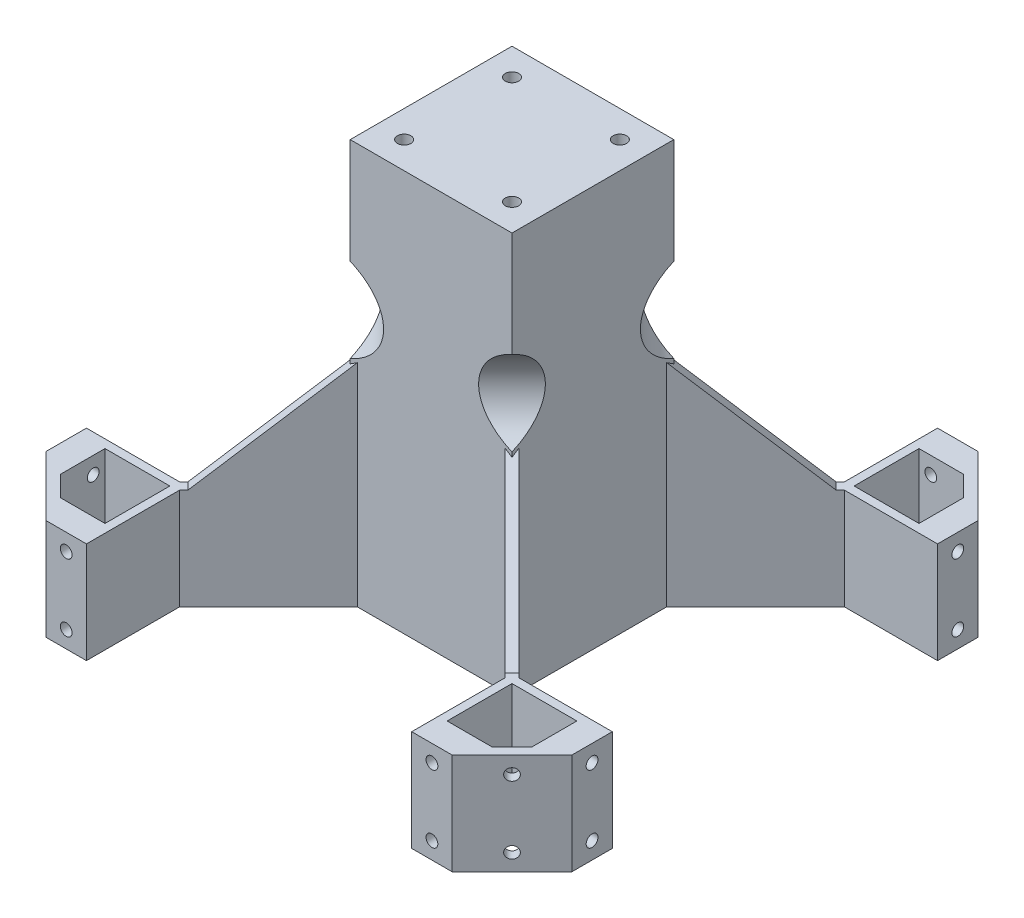
from build123d import *

# Parameters (mm, degrees)
BOSS_EXTRUDE1_DEPTH             = 30
SKETCH2_R                       = 1.75
CUT_EXTRUDE1_DEPTH              = 8
SKETCH5_R                       = 1.75
CUT_EXTRUDE2_DEPTH              = 3
BOSS_EXTRUDE2_DEPTH             = 3
CIRPATTERN5_COUNT               = 4
SKETCH4_W                       = 48
SKETCH4_H                       = 48
SKETCH4_W_2                     = 42
SKETCH4_H_2                     = 42
BOSS_EXTRUDE3_DEPTH             = 115
SKETCH6_W                       = 48
SKETCH6_H                       = 48
BOSS_EXTRUDE4_DEPTH             = 4
SKETCH7_R                       = 2
CUT_EXTRUDE3_DEPTH              = 4
CUT_EXTRUDE4_DEPTH              = 163.262133599
BOSS_EXTRUDE5_REACH             = 164.262
BOSS_EXTRUDE5_DIRECTION_2_REACH = 164.262
CIRPATTERN6_COUNT               = 4


with BuildPart() as part:
    # Sketch1 → Boss-Extrude1 (new body)
    with BuildSketch(Plane(origin=(0, 0, 0), x_dir=(1, 0, 0), z_dir=(0, 1, 0))):
        Polygon((48.25, -78), (48.25, -50.371320344), (20.152543264, -22.273863607), (21.213203436, -21.213203436), (50.75, -50.75), (50.75, -70), (64.007359313, -70), (67.003679656, -67.003679656), (69.125, -69.125), (60.25, -78), align=None)
    boss_extrude1 = extrude(amount=BOSS_EXTRUDE1_DEPTH)

    # Sketch2 → Cut-Extrude1 (cut)
    with BuildSketch(Plane.XY.offset(78)):
        with Locations((54.25, 5)):
            Circle(SKETCH2_R)
        with Locations((54.25, 25)):
            Circle(SKETCH2_R)
    cut_extrude1 = extrude(amount=-CUT_EXTRUDE1_DEPTH, mode=Mode.SUBTRACT)

    # Mirror1: Boss-Extrude1, Cut-Extrude1 across plane
    add(boss_extrude1.mirror(Plane(origin=(50.75, 30, 50.75), x_dir=(0.707106781186549, 0, 0.707106781186546), z_dir=(-0.707106781186546, 0, 0.707106781186549))))
    add(cut_extrude1.mirror(Plane(origin=(50.75, 30, 50.75), x_dir=(0.707106781186549, 0, 0.707106781186546), z_dir=(-0.707106781186546, 0, 0.707106781186549))), mode=Mode.SUBTRACT)

    # Sketch5 → Cut-Extrude2 (cut)
    with BuildSketch(Plane(origin=(69.125, 0, 69.125), x_dir=(0.7071067811865461, 0, -0.7071067811865489), z_dir=(0.7071067811865489, 0, 0.7071067811865461))):
        with Locations((0, 25)):
            Circle(SKETCH5_R)
        with Locations((0, 5)):
            Circle(SKETCH5_R)
    extrude(amount=-CUT_EXTRUDE2_DEPTH, mode=Mode.SUBTRACT)

    # Sketch3 → Boss-Extrude2 (add)
    with BuildSketch(Plane(origin=(-1.060660172, 0, 1.060660172), x_dir=(0.7071067811865492, 0, 0.7071067811865459), z_dir=(-0.7071067811865459, 0, 0.7071067811865492))):
        Polygon((30, 30), (30, 65), (68, 30), align=None)
    extrude(amount=-BOSS_EXTRUDE2_DEPTH)


with BuildPart() as cirpattern5_1:
    # CirPattern5: pattern copy
    add(part.part.rotate(Axis((0, 0, 0), (0, 1, 0)), 1 * 360 / CIRPATTERN5_COUNT))


with BuildPart() as cirpattern5_2:
    # CirPattern5: pattern copy
    add(part.part.rotate(Axis((0, 0, 0), (0, 1, 0)), 2 * 360 / CIRPATTERN5_COUNT))


with BuildPart() as cirpattern5_3:
    # CirPattern5: pattern copy
    add(part.part.rotate(Axis((0, 0, 0), (0, 1, 0)), 3 * 360 / CIRPATTERN5_COUNT))


with BuildPart() as part_1:
    add(part.part)

    add(cirpattern5_1.part)  # Boss-Extrude3 merges CirPattern5_1

    add(cirpattern5_2.part)  # Boss-Extrude3 merges CirPattern5_2

    add(cirpattern5_3.part)  # Boss-Extrude3 merges CirPattern5_3
    # Sketch4 → Boss-Extrude3 (add)
    with BuildSketch(Plane.XZ):
        Rectangle(SKETCH4_W, SKETCH4_H)
        Rectangle(SKETCH4_W_2, SKETCH4_H_2, mode=Mode.SUBTRACT)
    extrude(amount=-BOSS_EXTRUDE3_DEPTH)

    # Sketch6 → Boss-Extrude4 (add)
    with BuildSketch(Plane(origin=(0, 115, 0), x_dir=(1, 0, 0), z_dir=(0, 1, 0))):
        Rectangle(SKETCH6_W, SKETCH6_H)
    extrude(amount=BOSS_EXTRUDE4_DEPTH)

    # Sketch7 → Cut-Extrude3 (cut)
    with BuildSketch(Plane(origin=(0, 119, 0), x_dir=(1, 0, 0), z_dir=(0, 1, 0))):
        with Locations(Location((16, 16, 0), (0, 0, 270))):
            Circle(SKETCH7_R)
        with Locations(Location((-16, 16, 0), (0, 0, 270))):
            Circle(SKETCH7_R)
        with Locations(Location((-16, -16, 0), (0, 0, 270))):
            Circle(SKETCH7_R)
        with Locations(Location((16, -16, 0), (0, 0, 270))):
            Circle(SKETCH7_R)
    extrude(amount=-CUT_EXTRUDE3_DEPTH, mode=Mode.SUBTRACT)

    # Sketch8 → Cut-Extrude4 (cut, symmetric)
    with BuildSketch(Plane(origin=(0, 0, 0), x_dir=(0.7071067811865475, 0, -0.7071067811865477), z_dir=(0.7071067811865477, 0, 0.7071067811865475))):
        with BuildLine():
            Line((-33.941125497, 87.751594937), (-33.941125497, 62.751594937))
            ThreePointArc((-33.941125497, 62.751594937), (-26.941125497, 75.251594937), (-33.941125497, 87.751594937))
        make_face()
    cut_extrude4 = extrude(amount=CUT_EXTRUDE4_DEPTH, both=True, mode=Mode.SUBTRACT)

    # Sketch9 → Boss-Extrude5 (add, up to next)
    with BuildSketch(Plane(origin=(0, 0, 0), x_dir=(0.7071067811865475, 0, -0.7071067811865477), z_dir=(0.7071067811865477, 0, 0.7071067811865475)), mode=Mode.PRIVATE) as boss_extrude5_sk1:
        with BuildLine():
            Line((-29.69848481, 83.810022582), (-29.69848481, 88.298087549))
            ThreePointArc((-29.69848481, 88.298087549), (-23.941125497, 75.251594937), (-29.69848481, 62.205102325))
            Line((-29.69848481, 62.205102325), (-29.69848481, 66.693167292))
            ThreePointArc((-29.69848481, 66.693167292), (-26.941125497, 75.251594937), (-29.69848481, 83.810022582))
        make_face()
    boss_extrude5_tool1 = extrude(boss_extrude5_sk1.sketch, amount=BOSS_EXTRUDE5_REACH, mode=Mode.PRIVATE) - part_1.part
    boss_extrude5 = boss_extrude5_tool1.solids().sort_by_distance((-18.95893, 75.251595, 18.95893))[0]
    add(boss_extrude5)

    # Sketch9 → Boss-Extrude5 direction 2 (add, up to next)
    with BuildSketch(Plane(origin=(0, 0, 0), x_dir=(0.7071067811865475, 0, -0.7071067811865477), z_dir=(0.7071067811865477, 0, 0.7071067811865475)), mode=Mode.PRIVATE) as boss_extrude5_direction_2_sk1:
        with BuildLine():
            Line((-29.69848481, 83.810022582), (-29.69848481, 88.298087549))
            ThreePointArc((-29.69848481, 88.298087549), (-23.941125497, 75.251594937), (-29.69848481, 62.205102325))
            Line((-29.69848481, 62.205102325), (-29.69848481, 66.693167292))
            ThreePointArc((-29.69848481, 66.693167292), (-26.941125497, 75.251594937), (-29.69848481, 83.810022582))
        make_face()
    boss_extrude5_direction_2_tool1 = extrude(boss_extrude5_direction_2_sk1.sketch, amount=-BOSS_EXTRUDE5_DIRECTION_2_REACH, mode=Mode.PRIVATE) - part_1.part
    boss_extrude5_direction_2 = boss_extrude5_direction_2_tool1.solids().sort_by_distance((-18.95893, 75.251595, 18.95893))[0]
    add(boss_extrude5_direction_2)

    # CirPattern6: Cut-Extrude4, Boss-Extrude5, Boss-Extrude5 direction 2 ×4 about axis
    cirpattern6_axis = Axis((0, 31.5, 0), (0, -1, 0))
    add([cut_extrude4.rotate(cirpattern6_axis, i * 360 / CIRPATTERN6_COUNT) for i in range(1, CIRPATTERN6_COUNT)], mode=Mode.SUBTRACT)
    add([boss_extrude5.rotate(cirpattern6_axis, i * 360 / CIRPATTERN6_COUNT) for i in range(1, CIRPATTERN6_COUNT)])
    add([boss_extrude5_direction_2.rotate(cirpattern6_axis, i * 360 / CIRPATTERN6_COUNT) for i in range(1, CIRPATTERN6_COUNT)])


solid = part_1.part
